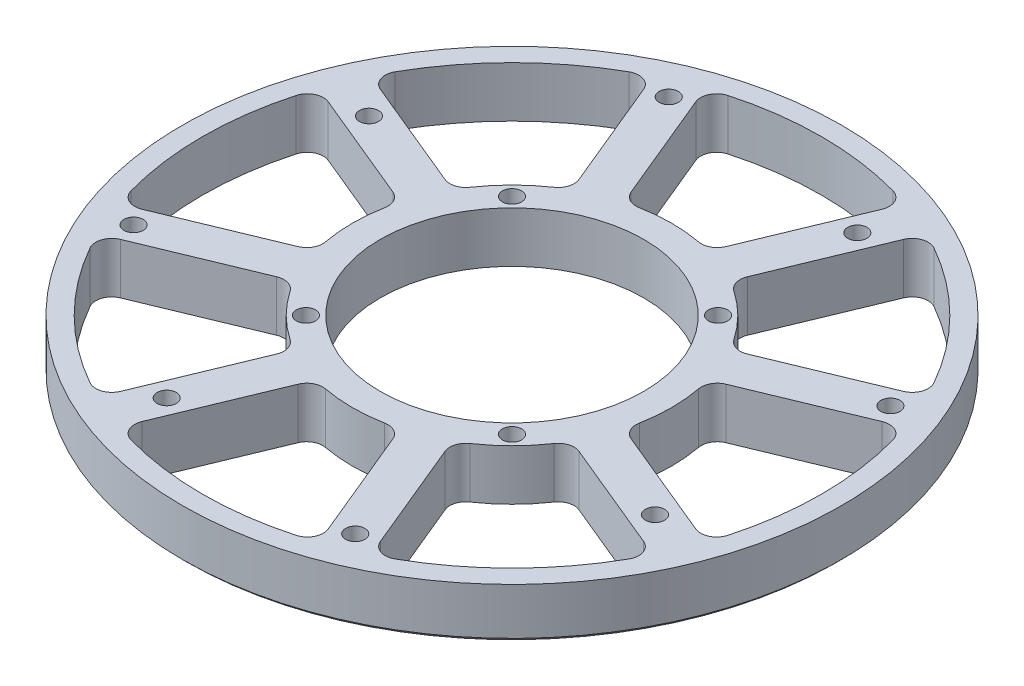
from build123d import *

# Parameters (mm, degrees)
SKETCH2_W                   = 82.55
SKETCH2_H                   = 12.7
F_12_0_189_DIAMETER_HOLE1_D = 4.8006
CIRPATTERN3_COUNT           = 4
CUT_EXTRUDE1_DEPTH          = 13.7
FILLET1_R                   = 4
CIRPATTERN4_COUNT           = 8
FILLET1_OF_CIRPATTERN4_R    = 4
CHAMFER2_SIZE               = 1
SKETCH9_R                   = 33
CUT_EXTRUDE2_DEPTH          = 13.7


with BuildPart() as part:
    # Sketch2 → Revolve1 (revolve)
    with BuildSketch(Plane(origin=(0, 0, 0), x_dir=(0, 0, -1), z_dir=(1, 0, 0))):
        with Locations((-41.275, 6.35)):
            Rectangle(SKETCH2_W, SKETCH2_H)
    revolve(axis=Axis((0, -0.635, 0), (0, 1, 0)))

    # #12 (0.189) Diameter Hole1 (through all)
    with Locations(Plane(origin=(0, 12.7, 0), x_dir=(1, 0, 0), z_dir=(0, 1, 0))):
        with Locations((-27.763683018, 67.027460084), (-61.160825052, 25.333643223), (-25.809397513, 25.809397513)):
            f_12_0_189_diameter_hole1 = Hole(F_12_0_189_DIAMETER_HOLE1_D / 2)

    # CirPattern3: #12 (0.189) Diameter Hole1 ×4 about axis
    cirpattern3_axis = Axis((0, 0, 0), (0, 1, 0))
    for i in range(1, CIRPATTERN3_COUNT):
        add(f_12_0_189_diameter_hole1.rotate(cirpattern3_axis, i * 360 / CIRPATTERN3_COUNT), mode=Mode.SUBTRACT)

    # Sketch8 → Cut-Extrude1 (cut, through all)
    with BuildSketch(Plane(origin=(0, 12.7, 0), x_dir=(1, 0, 0), z_dir=(0, 1, 0))):
        with BuildLine():
            Line((-10.567880231, 38.578749428), (-24.995954941, 73.411203073))
            ThreePointArc((-24.995954941, 73.411203073), (0, 77.55), (24.995954941, 73.411203073))
            Line((24.995954941, 73.411203073), (10.567880231, 38.578749428))
            ThreePointArc((10.567880231, 38.578749428), (0, 40), (-10.567880231, 38.578749428))
        make_face()
    cut_extrude1 = extrude(amount=-CUT_EXTRUDE1_DEPTH, mode=Mode.SUBTRACT)

    # Fillet1
    fillet1_edges = [part.edges().sort_by_distance(p)[0] for p in [
        (10.567880231, 6.35, -38.578749428),
        (-10.567880231, 6.35, -38.578749428),
        (-24.995954941, 6.35, -73.411203073),
        (24.995954941, 6.35, -73.411203073),
    ]]
    fillet(fillet1_edges, radius=FILLET1_R)

    # CirPattern4: Cut-Extrude1 ×8 about axis
    cirpattern4_axis = Axis((0, 0, 0), (0, 1, 0))
    for i in range(1, CIRPATTERN4_COUNT):
        add(cut_extrude1.rotate(cirpattern4_axis, i * 360 / CIRPATTERN4_COUNT), mode=Mode.SUBTRACT)

    # Fillet1 of CirPattern4
    fillet1_of_cirpattern4_edges = [part.edges().sort_by_distance(p)[0] for p in [
        (-19.806675556, 6.35, -34.751915104),
        (-34.751915104, 6.35, -19.806675556),
        (-69.584368749, 6.35, -34.234750266),
        (-34.234750266, 6.35, -69.584368749),
        (-38.578749428, 6.35, -10.567880231),
        (-38.578749428, 6.35, 10.567880231),
        (-73.411203073, 6.35, 24.995954941),
        (-73.411203073, 6.35, -24.995954941),
        (-34.751915104, 6.35, 19.806675556),
        (-19.806675556, 6.35, 34.751915104),
        (-34.234750266, 6.35, 69.584368749),
        (-69.584368749, 6.35, 34.234750266),
        (-10.567880231, 6.35, 38.578749428),
        (10.567880231, 6.35, 38.578749428),
        (24.995954941, 6.35, 73.411203073),
        (-24.995954941, 6.35, 73.411203073),
        (19.806675556, 6.35, 34.751915104),
        (34.751915104, 6.35, 19.806675556),
        (69.584368749, 6.35, 34.234750266),
        (34.234750266, 6.35, 69.584368749),
        (38.578749428, 6.35, 10.567880231),
        (38.578749428, 6.35, -10.567880231),
        (73.411203073, 6.35, -24.995954941),
        (73.411203073, 6.35, 24.995954941),
        (34.751915104, 6.35, -19.806675556),
        (19.806675556, 6.35, -34.751915104),
        (34.234750266, 6.35, -69.584368749),
        (69.584368749, 6.35, -34.234750266),
    ]]
    fillet(fillet1_of_cirpattern4_edges, radius=FILLET1_OF_CIRPATTERN4_R)

    # Chamfer2
    chamfer2_edges = [part.edges().sort_by_distance(p)[0] for p in [
        (0, 0, -82.55),
    ]]
    chamfer(chamfer2_edges, length=CHAMFER2_SIZE)

    # Sketch9 → Cut-Extrude2 (cut, through all)
    with BuildSketch(Plane(origin=(0, 12.7, 0), x_dir=(1, 0, 0), z_dir=(0, 1, 0))):
        Circle(SKETCH9_R)
    extrude(amount=-CUT_EXTRUDE2_DEPTH, mode=Mode.SUBTRACT)


solid = part.part
